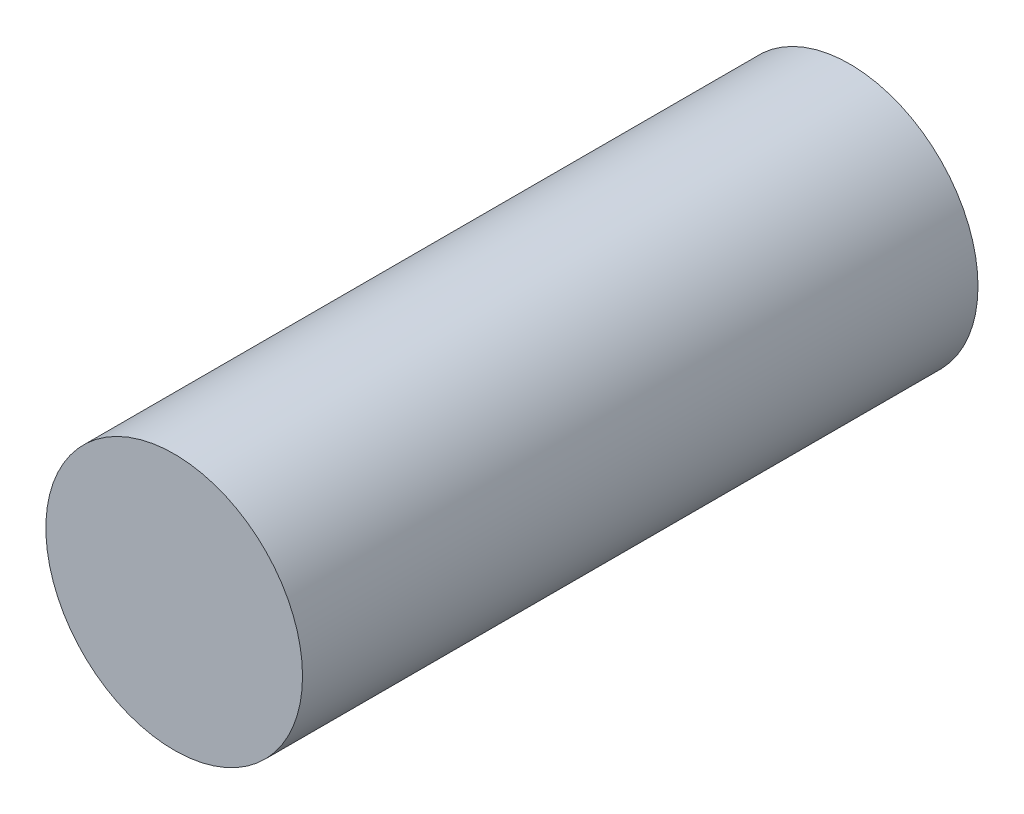
from build123d import *

# Parameters (mm, degrees)
SKETCH1_R           = 4.75
BOSS_EXTRUDE1_DEPTH = 25


with BuildPart() as part:
    # Sketch1 → Boss-Extrude1 (new body)
    with BuildSketch(Plane.XY):
        Circle(SKETCH1_R)
    extrude(amount=BOSS_EXTRUDE1_DEPTH)


solid = part.part
